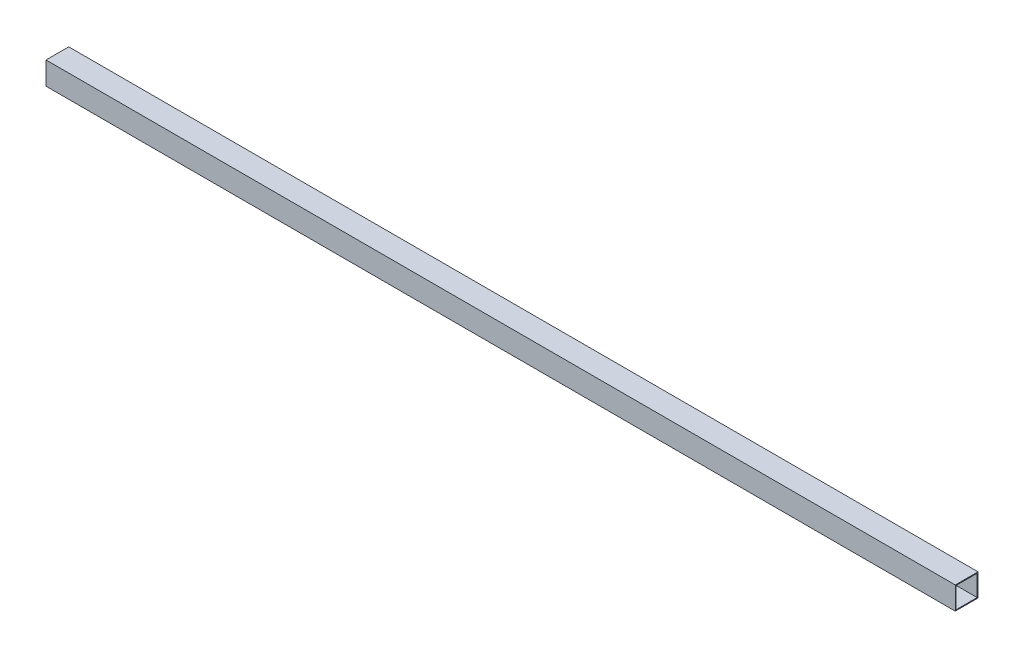
from build123d import *

# Parameters (mm, degrees)
ESBO_O1_W                = 40
ESBO_O1_H                = 40
RESSALTO_EXTRUS_O1_DEPTH = 1600
ESBO_O2_W                = 37
ESBO_O2_H                = 37
CORTE_EXTRUS_O1_DEPTH    = 1601


with BuildPart() as part:
    # Esboço1 → Ressalto-extrusão1 (new body)
    with BuildSketch(Plane(origin=(0, 0, 0), x_dir=(0, 0, -1), z_dir=(1, 0, 0))):
        Rectangle(ESBO_O1_W, ESBO_O1_H)
    extrude(amount=RESSALTO_EXTRUS_O1_DEPTH)

    # Esboço2 → Corte-extrusão1 (cut, through all)
    with BuildSketch(Plane.ZY):
        Rectangle(ESBO_O2_W, ESBO_O2_H)
    extrude(amount=-CORTE_EXTRUS_O1_DEPTH, mode=Mode.SUBTRACT)


solid = part.part
